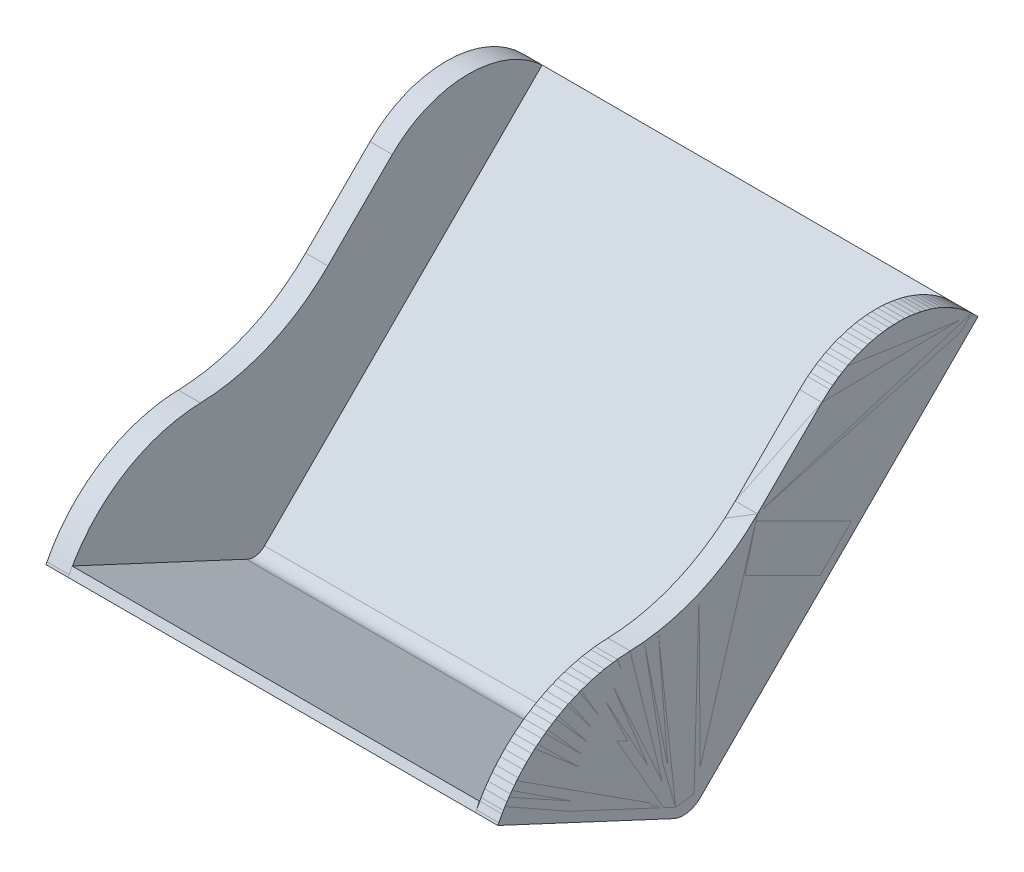
from build123d import *

# Parameters (mm, degrees)
EXTRUDE_THIN2_DEPTH = 228.6
BOSS_EXTRUDE1_DEPTH = 25
BOSS_EXTRUDE2_DEPTH = 25


with BuildPart() as part:
    # Sketch2 → Extrude-Thin2 (new, symmetric)
    with BuildSketch(Plane(origin=(0, 0, 0), x_dir=(0, 0, -1), z_dir=(1, 0, 0))):
        with BuildLine():
            Line((-215.765556665, 98.101326882), (-20.857742563, 7.214320532))
            ThreePointArc((-20.857742563, 7.214320532), (-3.885010881, 3.93226895), (11.605739191, 11.605739191))
            Line((11.605739191, 11.605739191), (323.289220358, 323.289220358))
            Line((323.289220358, 323.289220358), (316.218152547, 330.36028817))
            Line((316.218152547, 330.36028817), (4.534671379, 18.676807003))
            ThreePointArc((4.534671379, 18.676807003), (-5.401525765, 13.81913778), (-16.226282042, 16.088414212))
            Line((-16.226282042, 16.088414212), (-211.539374047, 107.164404752))
            Line((-211.539374047, 107.164404752), (-215.765556665, 98.101326882))
        make_face()
    extrude(amount=EXTRUDE_THIN2_DEPTH, both=True)


with BuildPart() as body_2:
    # Sketch3 → Boss-Extrude1 (new body)
    with BuildSketch(Plane(origin=(228.6, 0, 0), x_dir=(0, 0, -1), z_dir=(1, 0, 0))):
        with BuildLine():
            Line((4.534671379, 18.676807003), (316.170652418, 330.312788042))
            ThreePointArc((316.170652418, 330.312788042), (231.509072824, 362.926495212), (147.98120037, 327.509952779))
            Line((147.98120037, 327.509952779), (75.739307367, 255.268059776))
            ThreePointArc((75.739307367, 255.268059776), (10.125062359, 210.731135973), (-67.296210575, 193.563922251))
            ThreePointArc((-67.296210575, 193.563922251), (-150.544649092, 169.112572755), (-211.071774935, 106.946359705))
            Line((-211.071774935, 106.946359705), (-16.226282042, 16.088414212))
            ThreePointArc((-16.226282042, 16.088414212), (-5.401525765, 13.81913778), (4.534671379, 18.676807003))
        make_face()
    extrude(amount=BOSS_EXTRUDE1_DEPTH)


with BuildPart() as body_3:
    # Sketch3_3 → Boss-Extrude2 (new body)
    with BuildSketch(Plane(origin=(228.6, 0, 0), x_dir=(0, 0, -1), z_dir=(1, 0, 0))):
        with BuildLine():
            ThreePointArc((-20.857742563, 7.214320532), (-3.885010881, 3.93226895), (11.605739191, 11.605739191))
            Line((11.605739191, 11.605739191), (323.289220358, 323.289220358))
            Line((323.289220358, 323.289220358), (319.068487938, 327.509952779))
            ThreePointArc((319.068487938, 327.509952779), (233.524844154, 362.943290209), (147.98120037, 327.509952779))
            Line((147.98120037, 327.509952779), (75.739307367, 255.268059776))
            ThreePointArc((75.739307367, 255.268059776), (10.125062359, 210.731135973), (-67.296210575, 193.563922251))
            ThreePointArc((-67.296210575, 193.563922251), (-153.788956262, 167.108392258), (-214.682451636, 100.228856189))
            Line((-214.682451636, 100.228856189), (-215.765556665, 98.101326882))
            Line((-215.765556665, 98.101326882), (-20.857742563, 7.214320532))
        make_face()
    extrude(amount=BOSS_EXTRUDE2_DEPTH)


with BuildPart() as body_4:
    # Mirror11: mirrored copy
    add(body_3.part.mirror(Plane(origin=(0, 0, 0), x_dir=(0, 0, 1), z_dir=(1, 0, 0))))


solid = Compound([part.part, body_2.part, body_3.part, body_4.part])
